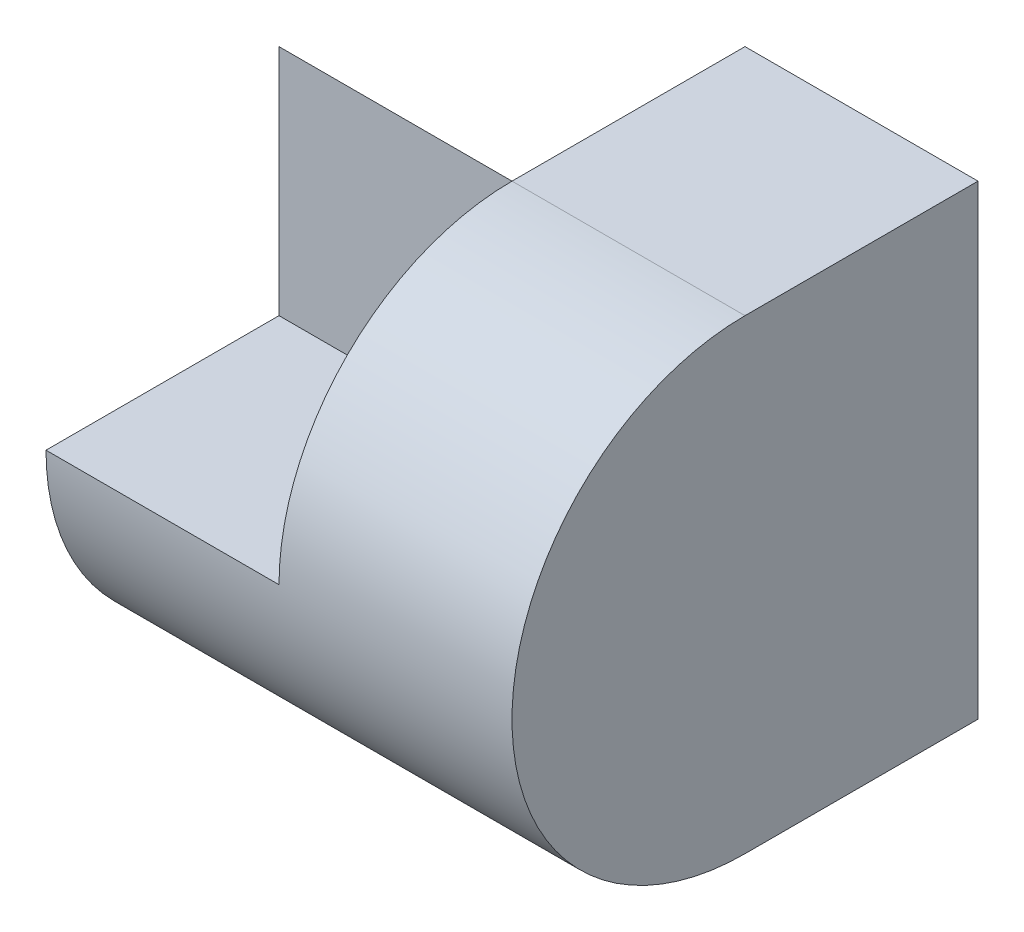
from build123d import *

# Parameters (mm, degrees)
SKETCH1_W           = 4
SKETCH1_H           = 4
BOSS_EXTRUDE1_DEPTH = 4
SKETCH2_W           = 2
SKETCH2_H           = 2
CUT_EXTRUDE1_DEPTH  = 2
CUT_EXTRUDE2_DEPTH  = 5


with BuildPart() as part:
    # Sketch1 → Boss-Extrude1 (new body)
    with BuildSketch(Plane(origin=(0, 0, 0), x_dir=(1, 0, 0), z_dir=(0, 1, 0))):
        Rectangle(SKETCH1_W, SKETCH1_H)
    extrude(amount=BOSS_EXTRUDE1_DEPTH)

    # Sketch2 → Cut-Extrude1 (cut)
    with BuildSketch(Plane.ZY.offset(2)):
        Polygon((-2, 4), (-2, 2), (0, 4), align=None)
        with Locations((1, 3)):
            Rectangle(SKETCH2_W, SKETCH2_H)
    extrude(amount=-CUT_EXTRUDE1_DEPTH, mode=Mode.SUBTRACT)

    # Sketch3 → Cut-Extrude2 (cut, symmetric)
    with BuildSketch(Plane.ZY):
        with BuildLine():
            ThreePointArc((0, 4), (1.414213562, 3.414213562), (2, 2))
            Line((2, 2), (2, 4))
            Line((2, 4), (0, 4))
        make_face()
        with BuildLine():
            Line((2, 0), (2, 2))
            ThreePointArc((2, 2), (1.414213562, 0.585786438), (0, 0))
            Line((0, 0), (2, 0))
        make_face()
    extrude(amount=CUT_EXTRUDE2_DEPTH, both=True, mode=Mode.SUBTRACT)


solid = part.part
